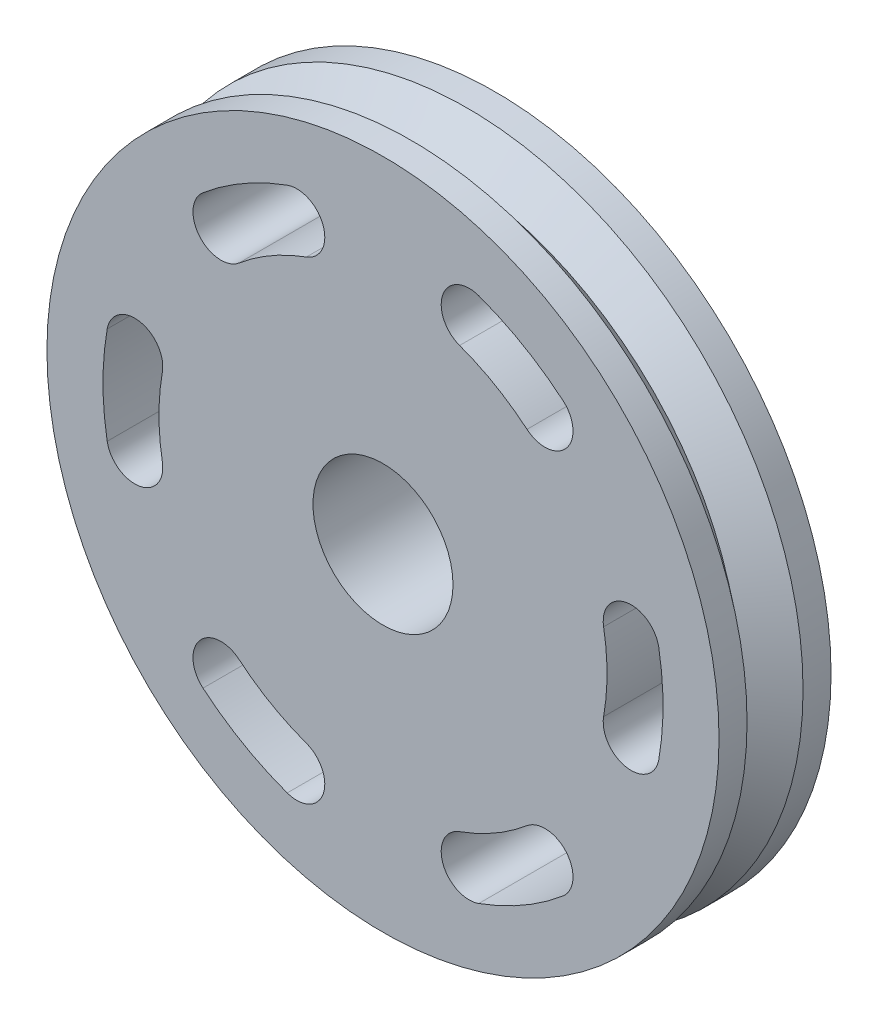
from build123d import *

# Parameters (mm, degrees)
SKETCH1_W          = 0.25
SKETCH1_H          = 3
SKETCH2_R          = 0.625
CUT_EXTRUDE1_DEPTH = 2


with BuildPart() as part:
    # Sketch1 → Revolve2 (revolve)
    with BuildSketch(Plane(origin=(0, 0, 0), x_dir=(0, 0, -1), z_dir=(1, 0, 0))):
        with Locations((-0.375, 1.5)):
            Rectangle(SKETCH1_W, SKETCH1_H)
        Polygon((0.25, 3), (0, 2.69), (-0.25, 3), (-0.25, 0), (0.25, 0), align=None)
        with Locations((0.375, 1.5)):
            Rectangle(SKETCH1_W, SKETCH1_H)
    revolve(axis=Axis((0, 0, 1.404515092), (0, 0, -1)))

    # Sketch2 → Cut-Extrude1 (cut, through all)
    with BuildSketch(Plane.XY.offset(0.5)):
        Circle(SKETCH2_R)
        with BuildLine():
            ThreePointArc((-2.462019383, 0.434120444), (-2.5, 0), (-2.462019383, -0.434120444))
            ThreePointArc((-2.462019383, -0.434120444), (-2.1724054, -0.636910338), (-1.969615506, -0.347296355))
            ThreePointArc((-1.969615506, -0.347296355), (-2, 0), (-1.969615506, 0.347296355))
            ThreePointArc((-1.969615506, 0.347296355), (-2.1724054, 0.636910338), (-2.462019383, 0.434120444))
        make_face()
        with BuildLine():
            ThreePointArc((-0.684040287, 1.879385242), (-1, 1.732050808), (-1.285575219, 1.532088886))
            ThreePointArc((-1.285575219, 1.532088886), (-1.637783233, 1.562903095), (-1.606969024, 1.915111108))
            ThreePointArc((-1.606969024, 1.915111108), (-1.25, 2.165063509), (-0.855050358, 2.349231552))
            ThreePointArc((-0.855050358, 2.349231552), (-0.534622167, 2.199813433), (-0.684040287, 1.879385242))
        make_face()
        with BuildLine():
            ThreePointArc((1.285575219, 1.532088886), (1, 1.732050808), (0.684040287, 1.879385242))
            ThreePointArc((0.684040287, 1.879385242), (0.534622167, 2.199813433), (0.855050358, 2.349231552))
            ThreePointArc((0.855050358, 2.349231552), (1.25, 2.165063509), (1.606969024, 1.915111108))
            ThreePointArc((1.606969024, 1.915111108), (1.637783233, 1.562903095), (1.285575219, 1.532088886))
        make_face()
        with BuildLine():
            ThreePointArc((1.969615506, -0.347296355), (2, 0), (1.969615506, 0.347296355))
            ThreePointArc((1.969615506, 0.347296355), (2.1724054, 0.636910338), (2.462019383, 0.434120444))
            ThreePointArc((2.462019383, 0.434120444), (2.5, 0), (2.462019383, -0.434120444))
            ThreePointArc((2.462019383, -0.434120444), (2.1724054, -0.636910338), (1.969615506, -0.347296355))
        make_face()
        with BuildLine():
            ThreePointArc((0.684040287, -1.879385242), (1, -1.732050808), (1.285575219, -1.532088886))
            ThreePointArc((1.285575219, -1.532088886), (1.637783233, -1.562903095), (1.606969024, -1.915111108))
            ThreePointArc((1.606969024, -1.915111108), (1.25, -2.165063509), (0.855050358, -2.349231552))
            ThreePointArc((0.855050358, -2.349231552), (0.534622167, -2.199813433), (0.684040287, -1.879385242))
        make_face()
        with BuildLine():
            ThreePointArc((-1.285575219, -1.532088886), (-1, -1.732050808), (-0.684040287, -1.879385242))
            ThreePointArc((-0.684040287, -1.879385242), (-0.534622167, -2.199813433), (-0.855050358, -2.349231552))
            ThreePointArc((-0.855050358, -2.349231552), (-1.25, -2.165063509), (-1.606969024, -1.915111108))
            ThreePointArc((-1.606969024, -1.915111108), (-1.637783233, -1.562903095), (-1.285575219, -1.532088886))
        make_face()
    extrude(amount=-CUT_EXTRUDE1_DEPTH, mode=Mode.SUBTRACT)


solid = part.part
